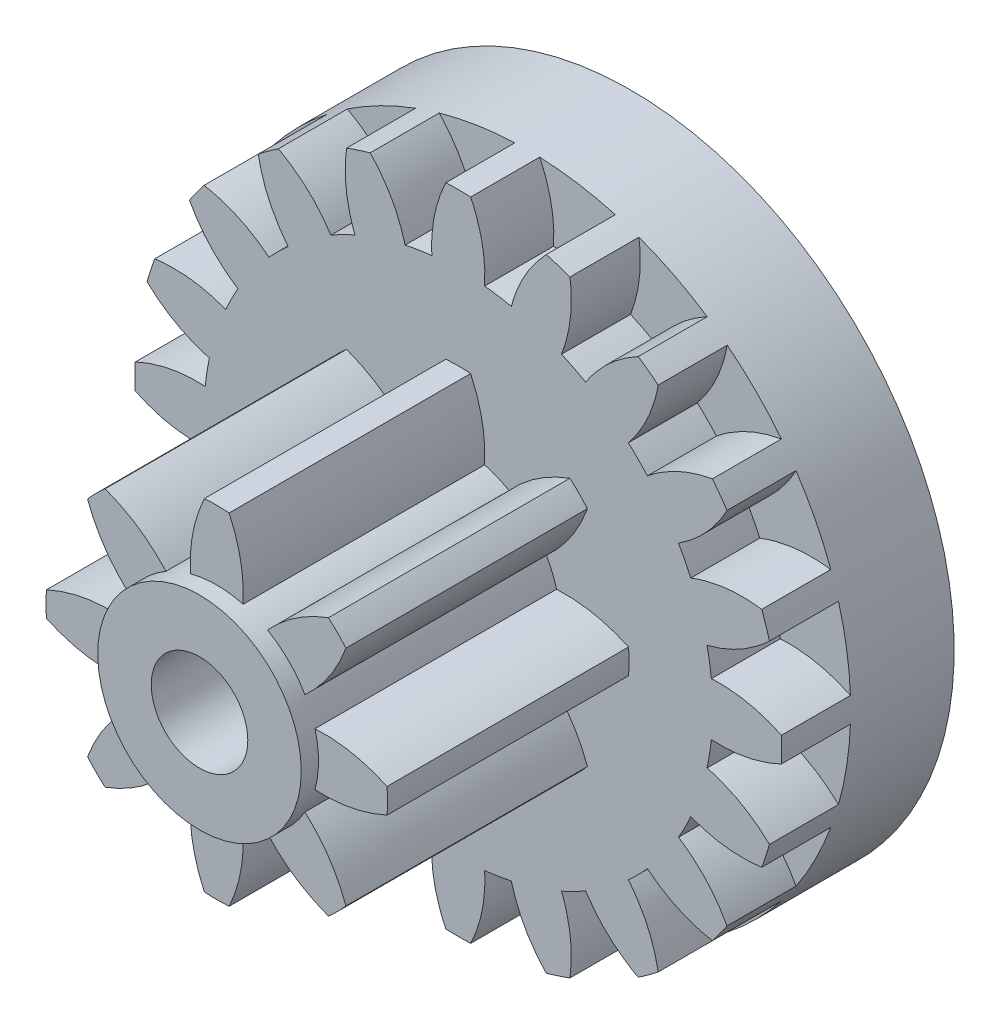
from build123d import *

# Parameters (mm, degrees)
EXTRUDE_1_DEPTH          = 0.5
SKETCH_2_R               = 1.25
EXTRUDE_2_DEPTH          = 0.25
EXTRUDE_3_DEPTH          = 3.5
SKETCH_4_R               = 0.7
CUT_EXTRUDE_1_DEPTH      = 5
CUT_EXTRUDE_1_DEPTH_BACK = 1.75
SKETCH_7_R               = 1.475
EXTRUDE_5_DEPTH          = 0.25
SKETCH_8_R               = 0.7
CUT_EXTRUDE_2_DEPTH      = 6
SKETCH_12_R              = 4.6875
EXTRUDE_6_DEPTH          = 1.5


with BuildPart() as part:
    # 草图1 → 凸台-拉伸1 (new body, symmetric)
    with BuildSketch(Plane.XY):
        with BuildLine():
            ThreePointArc((-0.382624, 3.667595), (-0.576852, 3.642101), (-0.769452, 3.606328))
            add(Edge.make_bspline(
                [(-1.276291, 4.510403), (-0.905966, 4.123291), (-0.769452, 3.606328)],
                knots=[0, 0, 0, 1, 1, 1], degree=2))
            ThreePointArc((-1.276291, 4.510403), (-1.448517, 4.458077), (-1.618608, 4.399178))
            add(Edge.make_bspline(
                [(-1.618608, 4.399178), (-1.690668, 3.868326), (-1.497246, 3.369853)],
                knots=[0, 0, 0, 1, 1, 1], degree=2))
            ThreePointArc((-1.497246, 3.369853), (-1.67409, 3.285587), (-1.846209, 3.192048))
            add(Edge.make_bspline(
                [(-2.607616, 3.895253), (-2.135792, 3.641524), (-1.846209, 3.192048)],
                knots=[0, 0, 0, 1, 1, 1], degree=2))
            ThreePointArc((-2.607616, 3.895253), (-2.755243, 3.792267), (-2.898808, 3.683689))
            add(Edge.make_bspline(
                [(-2.898808, 3.683689), (-2.803299, 3.156551), (-2.465308, 2.742246)],
                knots=[0, 0, 0, 1, 1, 1], degree=2))
            ThreePointArc((-2.465308, 2.742246), (-2.607456, 2.607456), (-2.742246, 2.465308))
            add(Edge.make_bspline(
                [(-3.683689, 2.898808), (-3.156551, 2.803299), (-2.742246, 2.465308)],
                knots=[0, 0, 0, 1, 1, 1], degree=2))
            ThreePointArc((-3.683689, 2.898808), (-3.792267, 2.755243), (-3.895253, 2.607616))
            add(Edge.make_bspline(
                [(-3.895253, 2.607616), (-3.641524, 2.135792), (-3.192048, 1.846209)],
                knots=[0, 0, 0, 1, 1, 1], degree=2))
            ThreePointArc((-3.192048, 1.846209), (-3.285587, 1.67409), (-3.369853, 1.497246))
            add(Edge.make_bspline(
                [(-4.399178, 1.618608), (-3.868326, 1.690668), (-3.369853, 1.497246)],
                knots=[0, 0, 0, 1, 1, 1], degree=2))
            ThreePointArc((-4.399178, 1.618608), (-4.458077, 1.448517), (-4.510403, 1.276291))
            add(Edge.make_bspline(
                [(-4.510403, 1.276291), (-4.123291, 0.905966), (-3.606328, 0.769452)],
                knots=[0, 0, 0, 1, 1, 1], degree=2))
            ThreePointArc((-3.606328, 0.769452), (-3.642101, 0.576852), (-3.667595, 0.382624))
            add(Edge.make_bspline(
                [(-4.684044, 0.179967), (-4.201441, 0.412542), (-3.667595, 0.382624)],
                knots=[0, 0, 0, 1, 1, 1], degree=2))
            ThreePointArc((-4.684044, 0.179967), (-4.6875, 0), (-4.684044, -0.179967))
            add(Edge.make_bspline(
                [(-4.684044, -0.179967), (-4.201441, -0.412542), (-3.667595, -0.382624)],
                knots=[0, 0, 0, 1, 1, 1], degree=2))
            ThreePointArc((-3.667595, -0.382624), (-3.642101, -0.576852), (-3.606328, -0.769452))
            add(Edge.make_bspline(
                [(-4.510403, -1.276291), (-4.123291, -0.905966), (-3.606328, -0.769452)],
                knots=[0, 0, 0, 1, 1, 1], degree=2))
            ThreePointArc((-4.510403, -1.276291), (-4.458077, -1.448517), (-4.399178, -1.618608))
            add(Edge.make_bspline(
                [(-4.399178, -1.618608), (-3.868326, -1.690668), (-3.369853, -1.497246)],
                knots=[0, 0, 0, 1, 1, 1], degree=2))
            ThreePointArc((-3.369853, -1.497246), (-3.285587, -1.67409), (-3.192048, -1.846209))
            add(Edge.make_bspline(
                [(-3.895253, -2.607616), (-3.641524, -2.135792), (-3.192048, -1.846209)],
                knots=[0, 0, 0, 1, 1, 1], degree=2))
            ThreePointArc((-3.895253, -2.607616), (-3.792267, -2.755243), (-3.683689, -2.898808))
            add(Edge.make_bspline(
                [(-3.683689, -2.898808), (-3.156551, -2.803299), (-2.742246, -2.465308)],
                knots=[0, 0, 0, 1, 1, 1], degree=2))
            ThreePointArc((-2.742246, -2.465308), (-2.607456, -2.607456), (-2.465308, -2.742246))
            add(Edge.make_bspline(
                [(-2.898808, -3.683689), (-2.803299, -3.156551), (-2.465308, -2.742246)],
                knots=[0, 0, 0, 1, 1, 1], degree=2))
            ThreePointArc((-2.898808, -3.683689), (-2.755243, -3.792267), (-2.607616, -3.895253))
            add(Edge.make_bspline(
                [(-2.607616, -3.895253), (-2.135792, -3.641524), (-1.846209, -3.192048)],
                knots=[0, 0, 0, 1, 1, 1], degree=2))
            ThreePointArc((-1.846209, -3.192048), (-1.67409, -3.285587), (-1.497246, -3.369853))
            add(Edge.make_bspline(
                [(-1.618608, -4.399178), (-1.690668, -3.868326), (-1.497246, -3.369853)],
                knots=[0, 0, 0, 1, 1, 1], degree=2))
            ThreePointArc((-1.618608, -4.399178), (-1.448517, -4.458077), (-1.276291, -4.510403))
            add(Edge.make_bspline(
                [(-1.276291, -4.510403), (-0.905966, -4.123291), (-0.769452, -3.606328)],
                knots=[0, 0, 0, 1, 1, 1], degree=2))
            ThreePointArc((-0.769452, -3.606328), (-0.576852, -3.642101), (-0.382624, -3.667595))
            add(Edge.make_bspline(
                [(-0.179967, -4.684044), (-0.412542, -4.201441), (-0.382624, -3.667595)],
                knots=[0, 0, 0, 1, 1, 1], degree=2))
            ThreePointArc((-0.179967, -4.684044), (0, -4.6875), (0.179967, -4.684044))
            add(Edge.make_bspline(
                [(0.179967, -4.684044), (0.412542, -4.201441), (0.382624, -3.667595)],
                knots=[0, 0, 0, 1, 1, 1], degree=2))
            ThreePointArc((0.382624, -3.667595), (0.576852, -3.642101), (0.769452, -3.606328))
            add(Edge.make_bspline(
                [(1.276291, -4.510403), (0.905966, -4.123291), (0.769452, -3.606328)],
                knots=[0, 0, 0, 1, 1, 1], degree=2))
            ThreePointArc((1.276291, -4.510403), (1.448517, -4.458077), (1.618608, -4.399178))
            add(Edge.make_bspline(
                [(1.618608, -4.399178), (1.690668, -3.868326), (1.497246, -3.369853)],
                knots=[0, 0, 0, 1, 1, 1], degree=2))
            ThreePointArc((1.497246, -3.369853), (1.67409, -3.285587), (1.846209, -3.192048))
            add(Edge.make_bspline(
                [(2.607616, -3.895253), (2.135792, -3.641524), (1.846209, -3.192048)],
                knots=[0, 0, 0, 1, 1, 1], degree=2))
            ThreePointArc((2.607616, -3.895253), (2.755243, -3.792267), (2.898808, -3.683689))
            add(Edge.make_bspline(
                [(2.898808, -3.683689), (2.803299, -3.156551), (2.465308, -2.742246)],
                knots=[0, 0, 0, 1, 1, 1], degree=2))
            ThreePointArc((2.465308, -2.742246), (2.607456, -2.607456), (2.742246, -2.465308))
            add(Edge.make_bspline(
                [(3.683689, -2.898808), (3.156551, -2.803299), (2.742246, -2.465308)],
                knots=[0, 0, 0, 1, 1, 1], degree=2))
            ThreePointArc((3.683689, -2.898808), (3.792267, -2.755243), (3.895253, -2.607616))
            add(Edge.make_bspline(
                [(3.895253, -2.607616), (3.641524, -2.135792), (3.192048, -1.846209)],
                knots=[0, 0, 0, 1, 1, 1], degree=2))
            ThreePointArc((3.192048, -1.846209), (3.285587, -1.67409), (3.369853, -1.497246))
            add(Edge.make_bspline(
                [(4.399178, -1.618608), (3.868326, -1.690668), (3.369853, -1.497246)],
                knots=[0, 0, 0, 1, 1, 1], degree=2))
            ThreePointArc((4.399178, -1.618608), (4.458077, -1.448517), (4.510403, -1.276291))
            add(Edge.make_bspline(
                [(4.510403, -1.276291), (4.123291, -0.905966), (3.606328, -0.769452)],
                knots=[0, 0, 0, 1, 1, 1], degree=2))
            ThreePointArc((3.606328, -0.769452), (3.642101, -0.576852), (3.667595, -0.382624))
            add(Edge.make_bspline(
                [(4.684044, -0.179967), (4.201441, -0.412542), (3.667595, -0.382624)],
                knots=[0, 0, 0, 1, 1, 1], degree=2))
            ThreePointArc((4.684044, -0.179967), (4.6875, 0), (4.684044, 0.179967))
            add(Edge.make_bspline(
                [(4.684044, 0.179967), (4.201441, 0.412542), (3.667595, 0.382624)],
                knots=[0, 0, 0, 1, 1, 1], degree=2))
            ThreePointArc((3.667595, 0.382624), (3.642101, 0.576852), (3.606328, 0.769452))
            add(Edge.make_bspline(
                [(4.510403, 1.276291), (4.123291, 0.905966), (3.606328, 0.769452)],
                knots=[0, 0, 0, 1, 1, 1], degree=2))
            ThreePointArc((4.510403, 1.276291), (4.458077, 1.448517), (4.399178, 1.618608))
            add(Edge.make_bspline(
                [(4.399178, 1.618608), (3.868326, 1.690668), (3.369853, 1.497246)],
                knots=[0, 0, 0, 1, 1, 1], degree=2))
            ThreePointArc((3.369853, 1.497246), (3.285587, 1.67409), (3.192048, 1.846209))
            add(Edge.make_bspline(
                [(3.895253, 2.607616), (3.641524, 2.135792), (3.192048, 1.846209)],
                knots=[0, 0, 0, 1, 1, 1], degree=2))
            ThreePointArc((3.895253, 2.607616), (3.792267, 2.755243), (3.683689, 2.898808))
            add(Edge.make_bspline(
                [(3.683689, 2.898808), (3.156551, 2.803299), (2.742246, 2.465308)],
                knots=[0, 0, 0, 1, 1, 1], degree=2))
            ThreePointArc((2.742246, 2.465308), (2.607456, 2.607456), (2.465308, 2.742246))
            add(Edge.make_bspline(
                [(2.898808, 3.683689), (2.803299, 3.156551), (2.465308, 2.742246)],
                knots=[0, 0, 0, 1, 1, 1], degree=2))
            ThreePointArc((2.898808, 3.683689), (2.755243, 3.792267), (2.607616, 3.895253))
            add(Edge.make_bspline(
                [(2.607616, 3.895253), (2.135792, 3.641524), (1.846209, 3.192048)],
                knots=[0, 0, 0, 1, 1, 1], degree=2))
            ThreePointArc((1.846209, 3.192048), (1.67409, 3.285587), (1.497246, 3.369853))
            add(Edge.make_bspline(
                [(1.618608, 4.399178), (1.690668, 3.868326), (1.497246, 3.369853)],
                knots=[0, 0, 0, 1, 1, 1], degree=2))
            ThreePointArc((1.618608, 4.399178), (1.448517, 4.458077), (1.276291, 4.510403))
            add(Edge.make_bspline(
                [(1.276291, 4.510403), (0.905966, 4.123291), (0.769452, 3.606328)],
                knots=[0, 0, 0, 1, 1, 1], degree=2))
            ThreePointArc((0.769452, 3.606328), (0.576852, 3.642101), (0.382624, 3.667595))
            add(Edge.make_bspline(
                [(0.179967, 4.684044), (0.412542, 4.201441), (0.382624, 3.667595)],
                knots=[0, 0, 0, 1, 1, 1], degree=2))
            ThreePointArc((0.179967, 4.684044), (0, 4.6875), (-0.179967, 4.684044))
            add(Edge.make_bspline(
                [(-0.179967, 4.684044), (-0.412542, 4.201441), (-0.382624, 3.667595)],
                knots=[0, 0, 0, 1, 1, 1], degree=2))
        make_face()
    extrude(amount=EXTRUDE_1_DEPTH, both=True)

    # 草图2 → 凸台-拉伸2 (add)
    with BuildSketch(Plane(origin=(0, 0, -0.5), x_dir=(-1, 0, 0), z_dir=(0, 0, -1))):
        Circle(SKETCH_2_R)
    extrude(amount=EXTRUDE_2_DEPTH)

    # 草图3 → 凸台-拉伸3 (add)
    with BuildSketch(Plane.XY.offset(0.5)):
        with BuildLine():
            ThreePointArc((-0.38325, 1.42434), (-0.564458, 1.362722), (-0.736162, 1.278159))
            add(Edge.make_bspline(
                [(-1.618266, 1.872656), (-1.103724, 1.68364), (-0.736162, 1.278159)],
                knots=[0, 0, 0, 1, 1, 1], degree=2))
            ThreePointArc((-1.618266, 1.872656), (-1.750131, 1.750047), (-1.872734, 1.618176))
            add(Edge.make_bspline(
                [(-1.872734, 1.618176), (-1.683579, 1.103731), (-1.278159, 0.736162)],
                knots=[0, 0, 0, 1, 1, 1], degree=2))
            ThreePointArc((-1.278159, 0.736162), (-1.362722, 0.564458), (-1.42434, 0.38325))
            add(Edge.make_bspline(
                [(-2.468455, 0.179881), (-1.970964, 0.410063), (-1.42434, 0.38325)],
                knots=[0, 0, 0, 1, 1, 1], degree=2))
            ThreePointArc((-2.468455, 0.179881), (-2.475, -6e-05), (-2.468446, -0.18))
            add(Edge.make_bspline(
                [(-2.468446, -0.18), (-1.970926, -0.410014), (-1.42434, -0.38325)],
                knots=[0, 0, 0, 1, 1, 1], degree=2))
            ThreePointArc((-1.42434, -0.38325), (-1.362722, -0.564458), (-1.278159, -0.736162))
            add(Edge.make_bspline(
                [(-1.872656, -1.618266), (-1.68364, -1.103724), (-1.278159, -0.736162)],
                knots=[0, 0, 0, 1, 1, 1], degree=2))
            ThreePointArc((-1.872656, -1.618266), (-1.750047, -1.750131), (-1.618176, -1.872734))
            add(Edge.make_bspline(
                [(-1.618176, -1.872734), (-1.103731, -1.683579), (-0.736162, -1.278159)],
                knots=[0, 0, 0, 1, 1, 1], degree=2))
            ThreePointArc((-0.736162, -1.278159), (-0.564458, -1.362722), (-0.38325, -1.42434))
            add(Edge.make_bspline(
                [(-0.179881, -2.468455), (-0.410063, -1.970964), (-0.38325, -1.42434)],
                knots=[0, 0, 0, 1, 1, 1], degree=2))
            ThreePointArc((-0.179881, -2.468455), (6e-05, -2.475), (0.18, -2.468446))
            add(Edge.make_bspline(
                [(0.18, -2.468446), (0.410014, -1.970926), (0.38325, -1.42434)],
                knots=[0, 0, 0, 1, 1, 1], degree=2))
            ThreePointArc((0.38325, -1.42434), (0.564458, -1.362722), (0.736162, -1.278159))
            add(Edge.make_bspline(
                [(1.618266, -1.872656), (1.103724, -1.68364), (0.736162, -1.278159)],
                knots=[0, 0, 0, 1, 1, 1], degree=2))
            ThreePointArc((1.618266, -1.872656), (1.750131, -1.750047), (1.872734, -1.618176))
            add(Edge.make_bspline(
                [(1.872734, -1.618176), (1.683579, -1.103731), (1.278159, -0.736162)],
                knots=[0, 0, 0, 1, 1, 1], degree=2))
            ThreePointArc((1.278159, -0.736162), (1.362722, -0.564458), (1.42434, -0.38325))
            add(Edge.make_bspline(
                [(2.468455, -0.179881), (1.970964, -0.410063), (1.42434, -0.38325)],
                knots=[0, 0, 0, 1, 1, 1], degree=2))
            ThreePointArc((2.468455, -0.179881), (2.475, 6e-05), (2.468446, 0.18))
            add(Edge.make_bspline(
                [(2.468446, 0.18), (1.970926, 0.410014), (1.42434, 0.38325)],
                knots=[0, 0, 0, 1, 1, 1], degree=2))
            ThreePointArc((1.42434, 0.38325), (1.362722, 0.564458), (1.278159, 0.736162))
            add(Edge.make_bspline(
                [(1.872656, 1.618266), (1.68364, 1.103724), (1.278159, 0.736162)],
                knots=[0, 0, 0, 1, 1, 1], degree=2))
            ThreePointArc((1.872656, 1.618266), (1.750047, 1.750131), (1.618176, 1.872734))
            add(Edge.make_bspline(
                [(1.618176, 1.872734), (1.103731, 1.683579), (0.736162, 1.278159)],
                knots=[0, 0, 0, 1, 1, 1], degree=2))
            ThreePointArc((0.736162, 1.278159), (0.564458, 1.362722), (0.38325, 1.42434))
            add(Edge.make_bspline(
                [(0.179881, 2.468455), (0.410063, 1.970964), (0.38325, 1.42434)],
                knots=[0, 0, 0, 1, 1, 1], degree=2))
            ThreePointArc((0.179881, 2.468455), (-6e-05, 2.475), (-0.18, 2.468446))
            add(Edge.make_bspline(
                [(-0.18, 2.468446), (-0.410014, 1.970926), (-0.38325, 1.42434)],
                knots=[0, 0, 0, 1, 1, 1], degree=2))
        make_face()
    extrude(amount=EXTRUDE_3_DEPTH)

    # 草图4 → 切除-拉伸1 (cut, two sides)
    with BuildSketch(Plane.XY) as cut_extrude_1_sk:
        Circle(SKETCH_4_R)
    extrude(amount=CUT_EXTRUDE_1_DEPTH, mode=Mode.SUBTRACT)
    extrude(cut_extrude_1_sk.sketch, amount=-CUT_EXTRUDE_1_DEPTH_BACK, mode=Mode.SUBTRACT)

    # 草图7 → 凸台-拉伸5 (add)
    with BuildSketch(Plane.XY.offset(4)):
        Circle(SKETCH_7_R)
    extrude(amount=EXTRUDE_5_DEPTH)

    # 草图8 → 切除-拉伸2 (cut, through all)
    with BuildSketch(Plane.XY.offset(4.25)):
        Circle(SKETCH_8_R)
    extrude(amount=-CUT_EXTRUDE_2_DEPTH, mode=Mode.SUBTRACT)

    # 草图12 → 凸台-拉伸6 (add)
    with BuildSketch(Plane(origin=(0, 0, -0.5), x_dir=(-1, 0, 0), z_dir=(0, 0, -1))):
        Circle(SKETCH_12_R)
    extrude(amount=EXTRUDE_6_DEPTH)


solid = part.part
